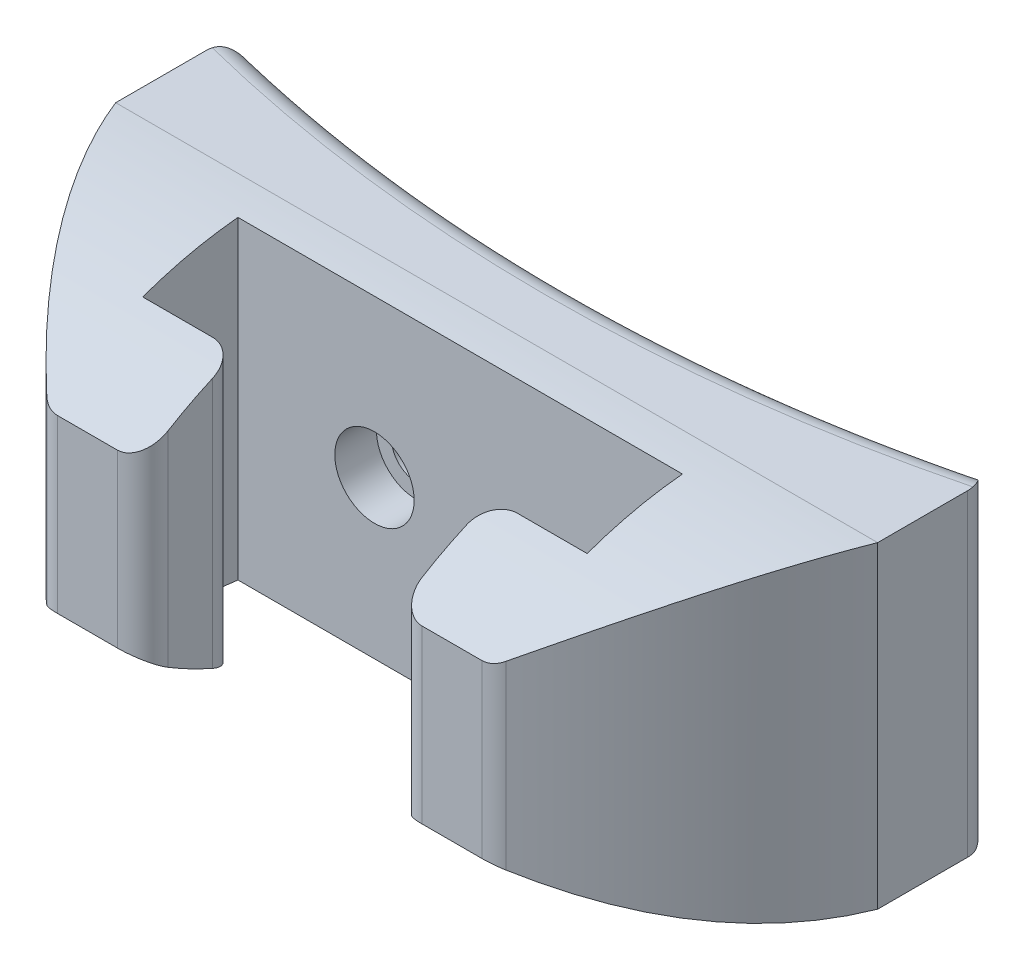
from build123d import *

# Parameters (mm, degrees)
BOSS_EXTRUDE1_DEPTH                            = 31.75
CBORE_FOR_8_SOCKET_HEAD_CAP_SCREW1_D           = 4.9149
CBORE_FOR_8_SOCKET_HEAD_CAP_SCREW1_CBORE_D     = 7.9375
CBORE_FOR_8_SOCKET_HEAD_CAP_SCREW1_CBORE_DEPTH = 4.1656
CUT_EXTRUDE1_DEPTH                             = 32.7500001
CUT_EXTRUDE3_DEPTH                             = 77.2000001
FILLET1_R                                      = 2.54
FILLET2_R                                      = 2.54
FILLET3_R                                      = 2.54


with BuildPart() as part:
    # Sketch1 → Boss-Extrude1 (new body)
    with BuildSketch(Plane(origin=(0, 0, 0), x_dir=(1, 0, 0), z_dir=(0, 1, 0))):
        with BuildLine():
            Line((38.1, 15.875), (38.1, -19.05))
            Line((38.1, -19.05), (12.7, -19.05))
            Line((12.7, -19.05), (12.7, -9.525))
            Line((12.7, -9.525), (22.225, -9.525))
            Line((22.225, -9.525), (22.225, 0))
            Line((22.225, 0), (-22.225, 0))
            Line((-22.225, 0), (-22.225, -9.525))
            Line((-22.225, -9.525), (-12.7, -9.525))
            Line((-12.7, -9.525), (-12.7, -19.05))
            Line((-12.7, -19.05), (-38.1, -19.05))
            Line((-38.1, -19.05), (-38.1, 15.875))
            ThreePointArc((-38.1, 15.875), (0, 11.035665491), (38.1, 15.875))
        make_face()
    extrude(amount=BOSS_EXTRUDE1_DEPTH)

    # CBORE for #8 Socket Head Cap Screw1 (through all)
    with Locations(Plane.XY):
        with Locations((-8.5725, 15.875), (8.5725, 15.875)):
            CounterBoreHole(CBORE_FOR_8_SOCKET_HEAD_CAP_SCREW1_D / 2, CBORE_FOR_8_SOCKET_HEAD_CAP_SCREW1_CBORE_D / 2, CBORE_FOR_8_SOCKET_HEAD_CAP_SCREW1_CBORE_DEPTH)

    # Sketch4 → Cut-Extrude1 (cut, through all)
    with BuildSketch(Plane(origin=(0, 31.75, 0), x_dir=(1, 0, 0), z_dir=(0, 1, 0))):
        with BuildLine():
            Line((-38.1, -19.05), (-38.1, 3.649511931))
            ThreePointArc((-38.1, 3.649511931), (-31.500580819, -8.639700689), (-22.216037286, -19.05))
            Line((-22.216037286, -19.05), (-38.1, -19.05))
        make_face()
    cut_extrude1 = extrude(amount=-CUT_EXTRUDE1_DEPTH, mode=Mode.SUBTRACT)

    # Mirror1: Cut-Extrude1 across plane
    add(cut_extrude1.mirror(Plane(origin=(0, 0, 0), x_dir=(0, 0, 1), z_dir=(1, 0, 0))), mode=Mode.SUBTRACT)

    # Sketch5 → Cut-Extrude3 (cut, through all)
    with BuildSketch(Plane.ZY.offset(38.1)):
        with BuildLine():
            Line((-3.649511931, 31.75), (19.05, 31.75))
            Line((19.05, 31.75), (19.05, 24.4475))
            ThreePointArc((19.05, 24.4475), (8.273096301, 29.879437004), (-3.649511931, 31.75))
        make_face()
        with BuildLine():
            ThreePointArc((19.05, 7.3025), (8.273096301, 1.870562996), (-3.649511931, 0))
            Line((-3.649511931, 0), (19.05, 0))
            Line((19.05, 0), (19.05, 7.3025))
        make_face()
    extrude(amount=-CUT_EXTRUDE3_DEPTH, mode=Mode.SUBTRACT)

    # Fillet1
    fillet1_edges = [part.edges().sort_by_distance(p)[0] for p in [
        (0, 0, -11.035665491),
        (38.1, 15.875, -15.875),
        (-38.1, 15.875, -15.875),
        (0, 31.75, -11.035665491),
    ]]
    fillet(fillet1_edges, radius=FILLET1_R)

    # Fillet2
    fillet2_edges = [part.edges().sort_by_distance(p)[0] for p in [
        (12.7, 15.875, 19.05),
        (12.7, 15.875, 9.525),
        (-12.7, 15.875, 9.525),
        (-12.7, 15.875, 19.05),
    ]]
    fillet(fillet2_edges, radius=FILLET2_R)

    # Fillet3
    fillet3_edges = [part.edges().sort_by_distance(p)[0] for p in [
        (22.216037286, 15.875, 19.05),
        (-22.216037286, 15.875, 19.05),
    ]]
    fillet(fillet3_edges, radius=FILLET3_R)


solid = part.part
